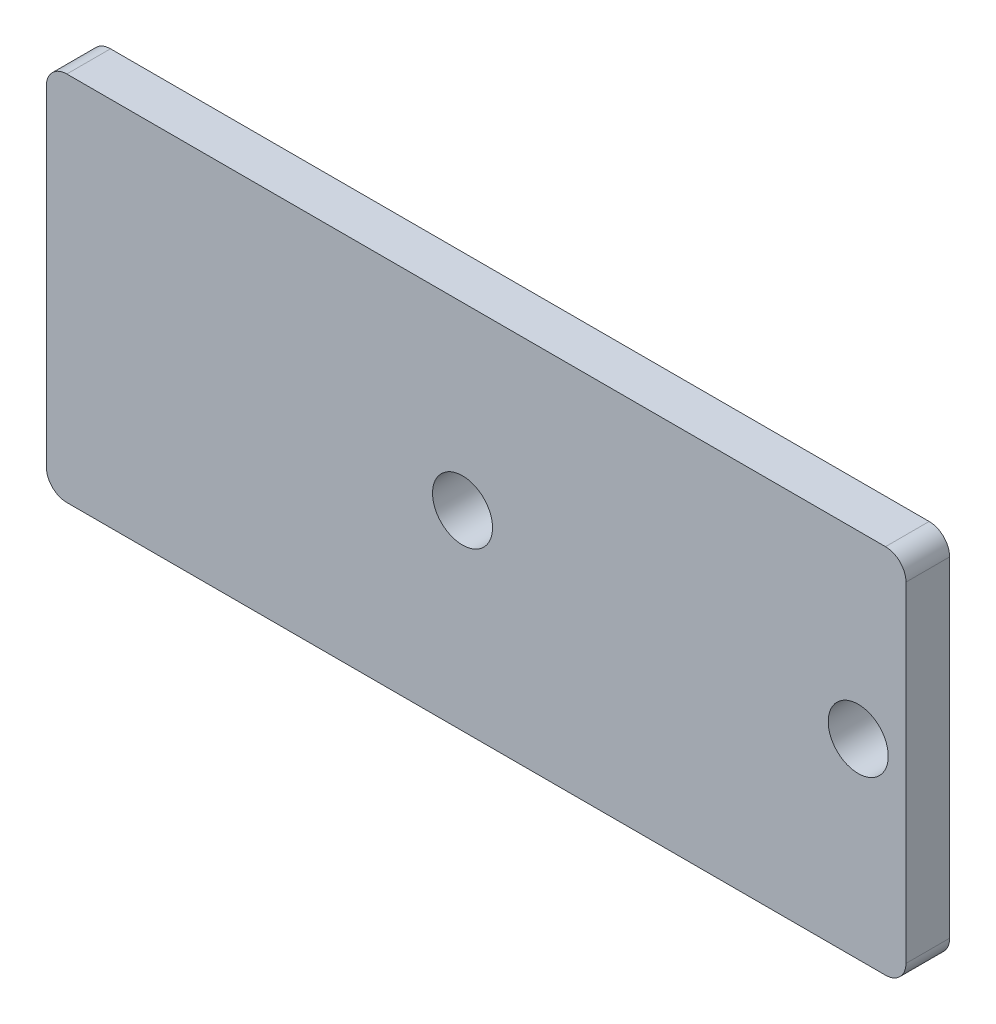
from build123d import *

# Parameters (mm, degrees)
MODEL_R             = 1.1
BOSS_EXTRUDE1_DEPTH = 0.8


with BuildPart() as part:
    # Model → Boss-Extrude1 (new body, symmetric)
    with BuildSketch(Plane.XY):
        with BuildLine():
            Line((-15, -6.8), (15, -6.8))
            ThreePointArc((15, -6.8), (15.530330086, -6.580330086), (15.75, -6.05))
            Line((15.75, -6.05), (15.75, 6.05))
            ThreePointArc((15.75, 6.05), (15.530330086, 6.580330086), (15, 6.8))
            Line((15, 6.8), (-15, 6.8))
            ThreePointArc((-15, 6.8), (-15.530330086, 6.580330086), (-15.75, 6.05))
            Line((-15.75, 6.05), (-15.75, -6.05))
            ThreePointArc((-15.75, -6.05), (-15.530330086, -6.580330086), (-15, -6.8))
        make_face()
        with Locations((-0.5, 0.2)):
            Circle(MODEL_R, mode=Mode.SUBTRACT)
        with Locations((14, 0.2)):
            Circle(MODEL_R, mode=Mode.SUBTRACT)
    extrude(amount=BOSS_EXTRUDE1_DEPTH, both=True)


solid = part.part
